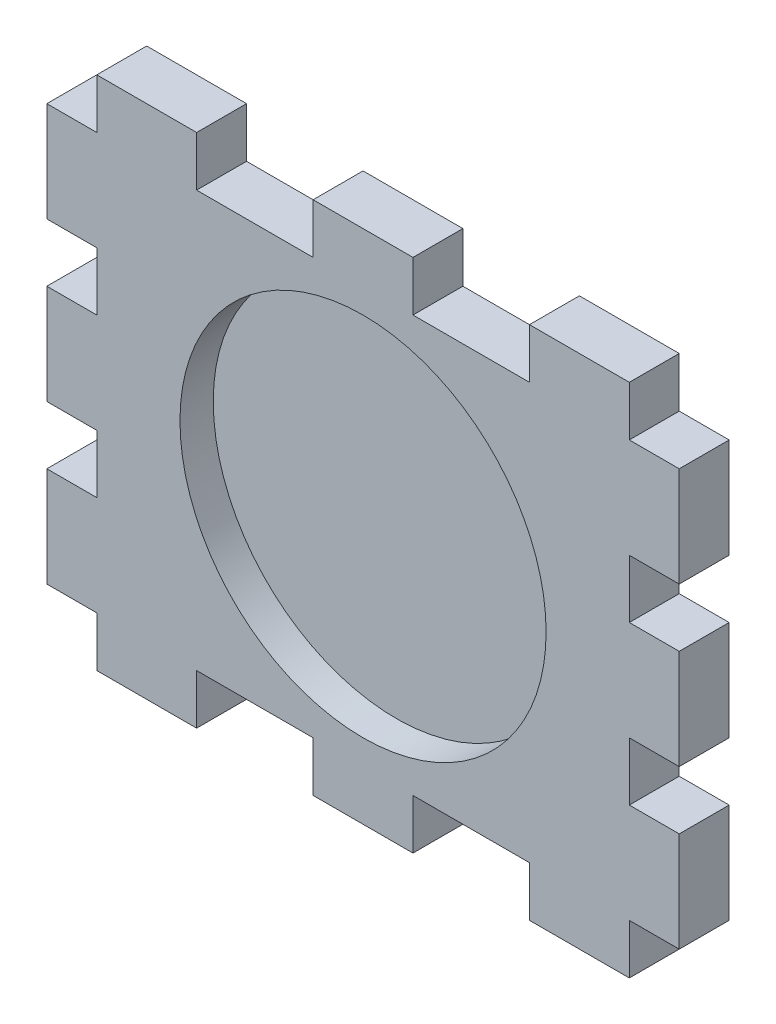
from build123d import *

# Parameters (mm, degrees)
SKETCH2_W           = 32
SKETCH2_H           = 25
SKETCH2_R           = 11
BOSS_EXTRUDE1_DEPTH = 3
SKETCH3_R           = 11
BOSS_EXTRUDE2_DEPTH = 1
SKETCH4_W           = 6
SKETCH4_H           = 3
SKETCH4_W_2         = 3
SKETCH4_H_2         = 6
BOSS_EXTRUDE3_DEPTH = 3


with BuildPart() as part:
    # Sketch2 → Boss-Extrude1 (new body)
    with BuildSketch(Plane.XY):
        Rectangle(SKETCH2_W, SKETCH2_H)
        Circle(SKETCH2_R, mode=Mode.SUBTRACT)
    extrude(amount=BOSS_EXTRUDE1_DEPTH)

    # Sketch3 → Boss-Extrude2 (add)
    with BuildSketch(Plane(origin=(0, 0, 0), x_dir=(-1, 0, 0), z_dir=(0, 0, -1))):
        Circle(SKETCH3_R)
    extrude(amount=-BOSS_EXTRUDE2_DEPTH)

    # Sketch4 → Boss-Extrude3 (add)
    with BuildSketch(Plane(origin=(0, 0, 0), x_dir=(-1, 0, 0), z_dir=(0, 0, -1))):
        with Locations((-13, -14)):
            Rectangle(SKETCH4_W, SKETCH4_H)
        with Locations((-17.5, -9.5)):
            Rectangle(SKETCH4_W_2, SKETCH4_H_2)
        with Locations((-17.5, 0)):
            Rectangle(SKETCH4_W_2, SKETCH4_H_2)
        with Locations((-17.5, 9.5)):
            Rectangle(SKETCH4_W_2, SKETCH4_H_2)
        with Locations((0, 14)):
            Rectangle(SKETCH4_W, SKETCH4_H)
        with Locations((13, 14)):
            Rectangle(SKETCH4_W, SKETCH4_H)
        with Locations((17.5, 9.5)):
            Rectangle(SKETCH4_W_2, SKETCH4_H_2)
        with Locations((17.5, 0)):
            Rectangle(SKETCH4_W_2, SKETCH4_H_2)
        with Locations((17.5, -9.5)):
            Rectangle(SKETCH4_W_2, SKETCH4_H_2)
        with Locations((13, -14)):
            Rectangle(SKETCH4_W, SKETCH4_H)
        with Locations((0, -14)):
            Rectangle(SKETCH4_W, SKETCH4_H)
        with Locations((-13, 14)):
            Rectangle(SKETCH4_W, SKETCH4_H)
    extrude(amount=-BOSS_EXTRUDE3_DEPTH)


solid = part.part
